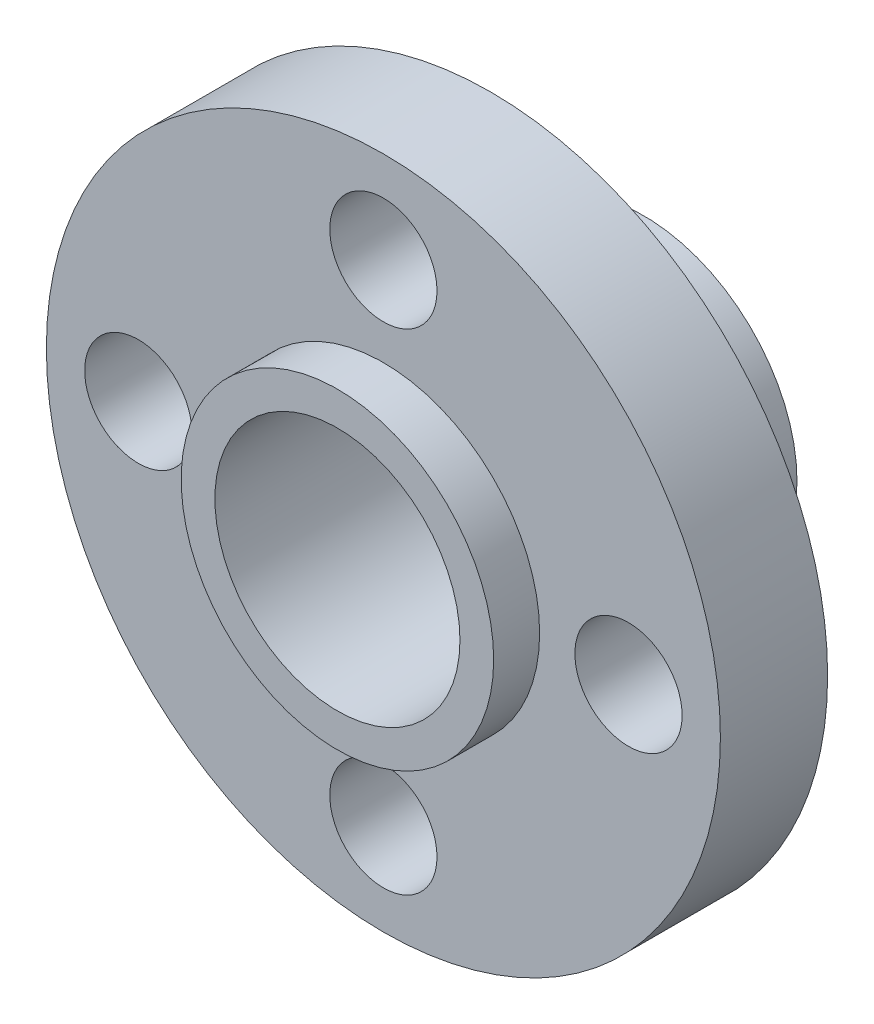
from build123d import *

# Parameters (mm, degrees)
SKETCH_1_R          = 11
SKETCH_1_R_2        = 1.75
EXTRUDE_2_DEPTH     = 3.5
SKETCH_2_R          = 5.1
EXTRUDE_4_DEPTH     = 1.5
SKETCH_3_R          = 5
EXTRUDE_5_DEPTH     = 5
SKETCH_4_R          = 4
CUT_EXTRUDE_4_DEPTH = 11


with BuildPart() as part:
    # 草圖1 → 填料-伸長2 (new body)
    with BuildSketch(Plane.XY):
        Circle(SKETCH_1_R)
        with Locations((0, 8)):
            Circle(SKETCH_1_R_2, mode=Mode.SUBTRACT)
        with Locations((8, 0)):
            Circle(SKETCH_1_R_2, mode=Mode.SUBTRACT)
        with Locations((0, -8)):
            Circle(SKETCH_1_R_2, mode=Mode.SUBTRACT)
        with Locations((-8, 0)):
            Circle(SKETCH_1_R_2, mode=Mode.SUBTRACT)
    extrude(amount=EXTRUDE_2_DEPTH)

    # 草圖2 → 填料-伸長4 (add)
    with BuildSketch(Plane.XY.offset(3.5)):
        Circle(SKETCH_2_R)
    extrude(amount=EXTRUDE_4_DEPTH)

    # 草圖3 → 填料-伸長5 (add)
    with BuildSketch(Plane(origin=(0, 0, 0), x_dir=(-1, 0, 0), z_dir=(0, 0, -1))):
        Circle(SKETCH_3_R)
    extrude(amount=EXTRUDE_5_DEPTH)

    # 草圖4 → 除料-伸長4 (cut, through all)
    with BuildSketch(Plane.XY.offset(5)):
        Circle(SKETCH_4_R)
    extrude(amount=-CUT_EXTRUDE_4_DEPTH, mode=Mode.SUBTRACT)


solid = part.part
